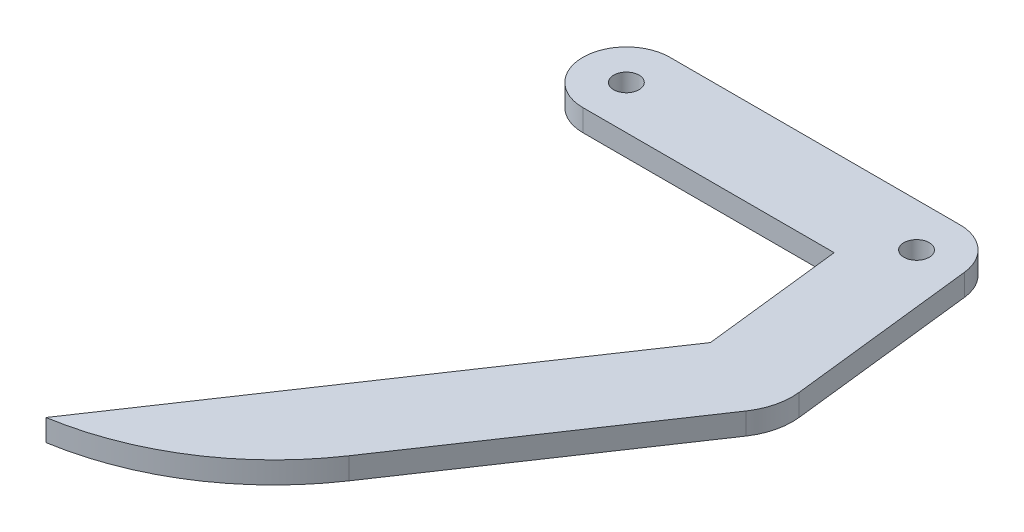
from build123d import *

# Parameters (mm, degrees)
SKETCH_1_R      = 1.75
EXTRUDE_1_DEPTH = 3


with BuildPart() as part:
    # 草圖1 → 填料-伸長1 (new body)
    with BuildSketch(Plane(origin=(0, 0, 0), x_dir=(1, 0, 0), z_dir=(0, 1, 0))):
        with BuildLine():
            Line((36.848566664, -25.260597764), (0, -80))
            ThreePointArc((0, -80), (14.411400344, -74.478032661), (25.446019232, -63.68832603))
            Line((25.446019232, -63.68832603), (47.47618504, -30.962002684))
            ThreePointArc((47.47618504, -30.962002684), (48.715425732, -28.156234166), (48.907790247, -25.095017029))
            Line((48.907790247, -25.095017029), (45.961176943, 0.681446592))
            ThreePointArc((45.961176943, 0.681446592), (43.994453683, 4.477090548), (40, 6))
            Line((40, 6), (0, 6))
            ThreePointArc((0, 6), (-6, 0), (0, -6))
            Line((0, -6), (34.646808717, -6))
            Line((34.646808717, -6), (36.848566664, -25.260597764))
        make_face()
        with Locations((40, 0)):
            Circle(SKETCH_1_R, mode=Mode.SUBTRACT)
        Circle(SKETCH_1_R, mode=Mode.SUBTRACT)
    extrude(amount=EXTRUDE_1_DEPTH)


solid = part.part
